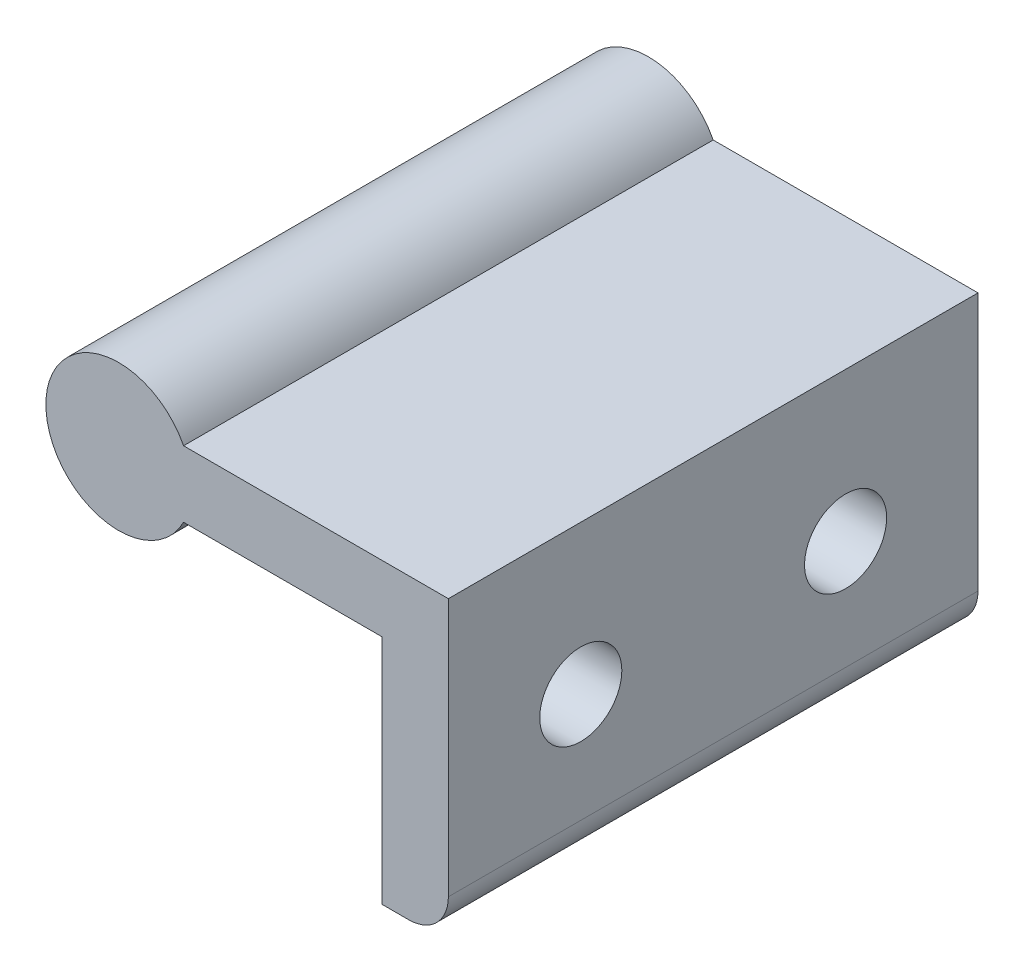
from build123d import *

# Parameters (mm, degrees)
SKETCH1_W           = 5
SKETCH1_H           = 17.5
BOSS_EXTRUDE1_DEPTH = 40
SKETCH2_R           = 3.1
CUT_EXTRUDE1_DEPTH  = 10
FILLET1_R           = 3


with BuildPart() as part:
    # Sketch1 → Boss-Extrude1 (new body)
    with BuildSketch(Plane.XY):
        with BuildLine():
            ThreePointArc((5.5, 0), (5.347634392, 1.285615189), (4.898979486, 2.5))
            Line((4.898979486, 2.5), (4.898979486, -2.5))
            ThreePointArc((4.898979486, -2.5), (5.347634392, -1.285615189), (5.5, 0))
        make_face()
        with BuildLine():
            Line((24.898979486, 2.5), (4.898979486, 2.5))
            ThreePointArc((4.898979486, 2.5), (5.347634392, 1.285615189), (5.5, 0))
            ThreePointArc((5.5, 0), (5.347634392, -1.285615189), (4.898979486, -2.5))
            Line((4.898979486, -2.5), (19.898979486, -2.5))
            Line((19.898979486, -2.5), (24.898979486, -2.5))
            Line((24.898979486, -2.5), (24.898979486, 2.5))
        make_face()
        with BuildLine():
            Line((4.898979486, -2.5), (4.898979486, 2.5))
            ThreePointArc((4.898979486, 2.5), (-5.5, 0), (4.898979486, -2.5))
        make_face()
        with Locations((22.398979486, -11.25)):
            Rectangle(SKETCH1_W, SKETCH1_H)
    extrude(amount=BOSS_EXTRUDE1_DEPTH)

    # Sketch2 → Cut-Extrude1 (cut)
    with BuildSketch(Plane(origin=(24.898979486, 0, 0), x_dir=(0, 0, -1), z_dir=(1, 0, 0))):
        with Locations((-30, -8.75)):
            Circle(SKETCH2_R)
        with Locations((-10, -8.75)):
            Circle(SKETCH2_R)
    extrude(amount=-CUT_EXTRUDE1_DEPTH, mode=Mode.SUBTRACT)

    # Fillet1
    fillet1_edges = [part.edges().sort_by_distance(p)[0] for p in [
        (24.898979486, -20, 20),
    ]]
    fillet(fillet1_edges, radius=FILLET1_R)


solid = part.part
